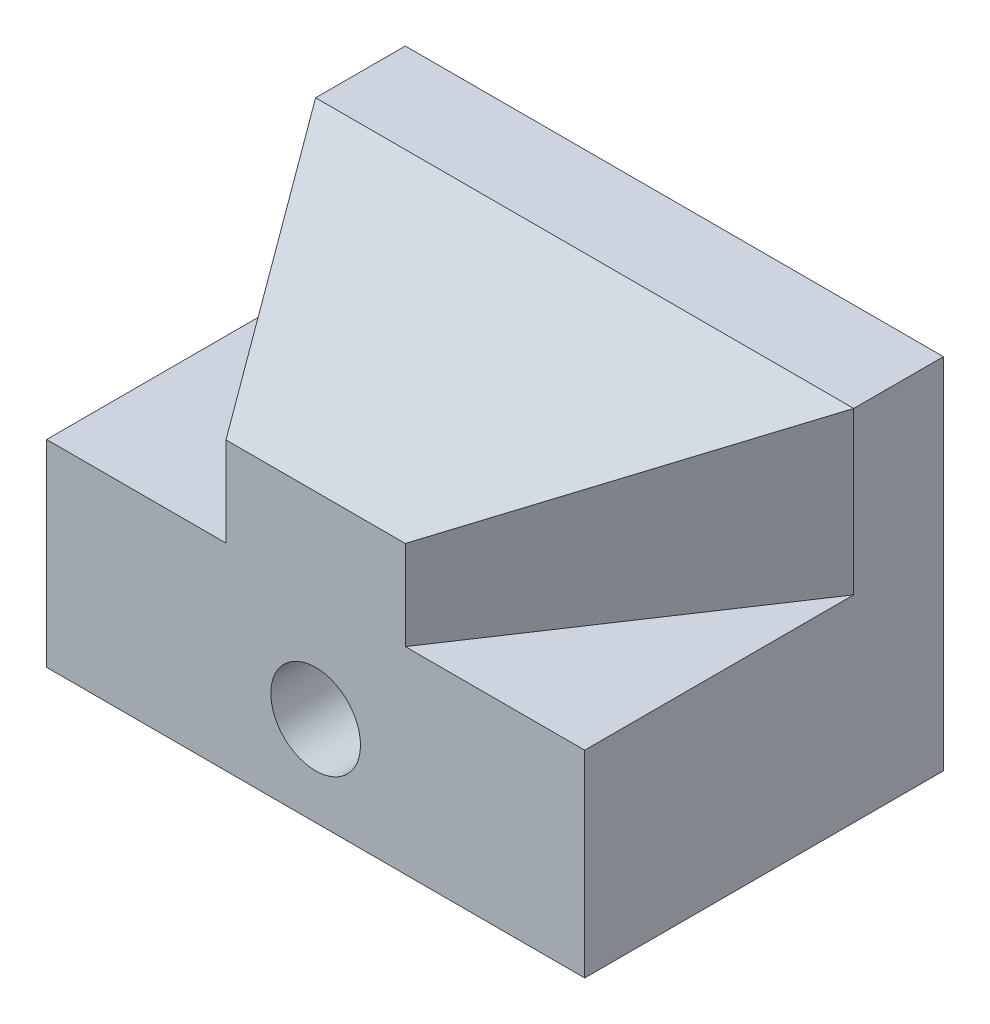
from build123d import *

# Parameters (mm, degrees)
SKETCH1_W               = 76.2
SKETCH1_H               = 50.8
BOSS_EXTRUDE1_DEPTH     = 50.8
CUT_EXTRUDE1_DEPTH      = 1
CUT_EXTRUDE1_DEPTH_BACK = 22.86
CUT_EXTRUDE2_DEPTH      = 77.2
SKETCH6_R               = 6.35
CUT_EXTRUDE3_DEPTH      = 51.8


with BuildPart() as part:
    # Sketch1 → Boss-Extrude1 (new body)
    with BuildSketch(Plane.XY):
        with Locations((38.1, 25.4)):
            Rectangle(SKETCH1_W, SKETCH1_H)
    extrude(amount=BOSS_EXTRUDE1_DEPTH)

    # Sketch2 → Cut-Extrude1 (cut, two sides)
    with BuildSketch(Plane(origin=(0, 50.8, 0), x_dir=(1, 0, 0), z_dir=(0, 1, 0))) as cut_extrude1_sk:
        Polygon((76.2, -12.7), (50.8, -50.8), (76.2, -50.8), align=None)
        Polygon((0, -12.7), (0, -50.8), (25.4, -50.8), align=None)
    extrude(amount=CUT_EXTRUDE1_DEPTH, mode=Mode.SUBTRACT)
    extrude(cut_extrude1_sk.sketch, amount=-CUT_EXTRUDE1_DEPTH_BACK, mode=Mode.SUBTRACT)

    # Sketch3 → Cut-Extrude2 (cut, through all)
    with BuildSketch(Plane(origin=(76.2, 0, 0), x_dir=(0, 0, -1), z_dir=(1, 0, 0))):
        Polygon((-12.7, 50.8), (-50.8, 40.591135768), (-50.8, 50.8), align=None)
    extrude(amount=-CUT_EXTRUDE2_DEPTH, mode=Mode.SUBTRACT)

    # Sketch6 → Cut-Extrude3 (cut, through all)
    with BuildSketch(Plane.XY.offset(50.8)):
        with Locations((38.1, 12.7)):
            Circle(SKETCH6_R)
    extrude(amount=-CUT_EXTRUDE3_DEPTH, mode=Mode.SUBTRACT)


solid = part.part
